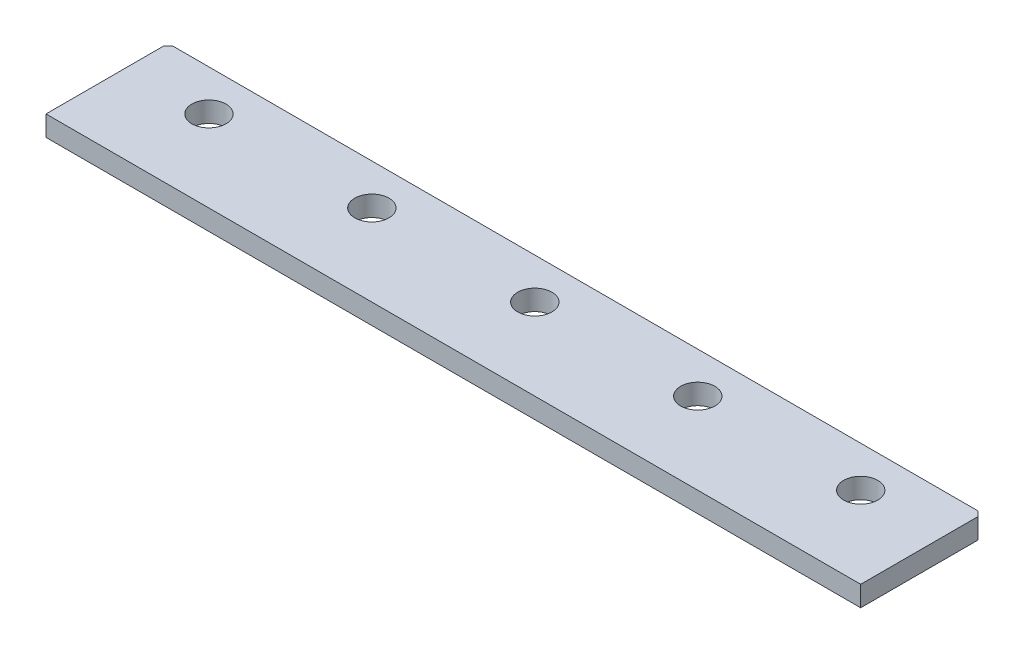
from build123d import *

# Parameters (mm, degrees)
SKETCH1_W           = 127
SKETCH1_H           = 19.05
BOSS_EXTRUDE1_DEPTH = 3.175
SKETCH2_R           = 2.667
CUT_EXTRUDE1_DEPTH  = 3.175
CUT_EXTRUDE2_DEPTH  = 3.175


with BuildPart() as part:
    # Sketch1 → Boss-Extrude1 (new body)
    with BuildSketch(Plane(origin=(0, 0, 0), x_dir=(1, 0, 0), z_dir=(0, 1, 0))):
        Rectangle(SKETCH1_W, SKETCH1_H)
    extrude(amount=BOSS_EXTRUDE1_DEPTH)

    # Sketch2 → Cut-Extrude1 (cut)
    with BuildSketch(Plane(origin=(0, 3.175, 0), x_dir=(1, 0, 0), z_dir=(0, 1, 0))):
        with Locations((50.8, 3.175)):
            Circle(SKETCH2_R)
        with Locations((25.4, 3.175)):
            Circle(SKETCH2_R)
        with Locations((0, 3.175)):
            Circle(SKETCH2_R)
        with Locations((-25.4, 3.175)):
            Circle(SKETCH2_R)
        with Locations((-50.8, 3.175)):
            Circle(SKETCH2_R)
    extrude(amount=-CUT_EXTRUDE1_DEPTH, mode=Mode.SUBTRACT)

    # Sketch3 → Cut-Extrude2 (cut)
    with BuildSketch(Plane(origin=(0, 3.175, 0), x_dir=(1, 0, 0), z_dir=(0, 1, 0))):
        Polygon((-63.5, 9.525), (-63.5, 8.763), (-62.738, 9.525), align=None)
        Polygon((63.5, 9.525), (63.5, 8.763), (62.738, 9.525), align=None)
    extrude(amount=-CUT_EXTRUDE2_DEPTH, mode=Mode.SUBTRACT)


solid = part.part
